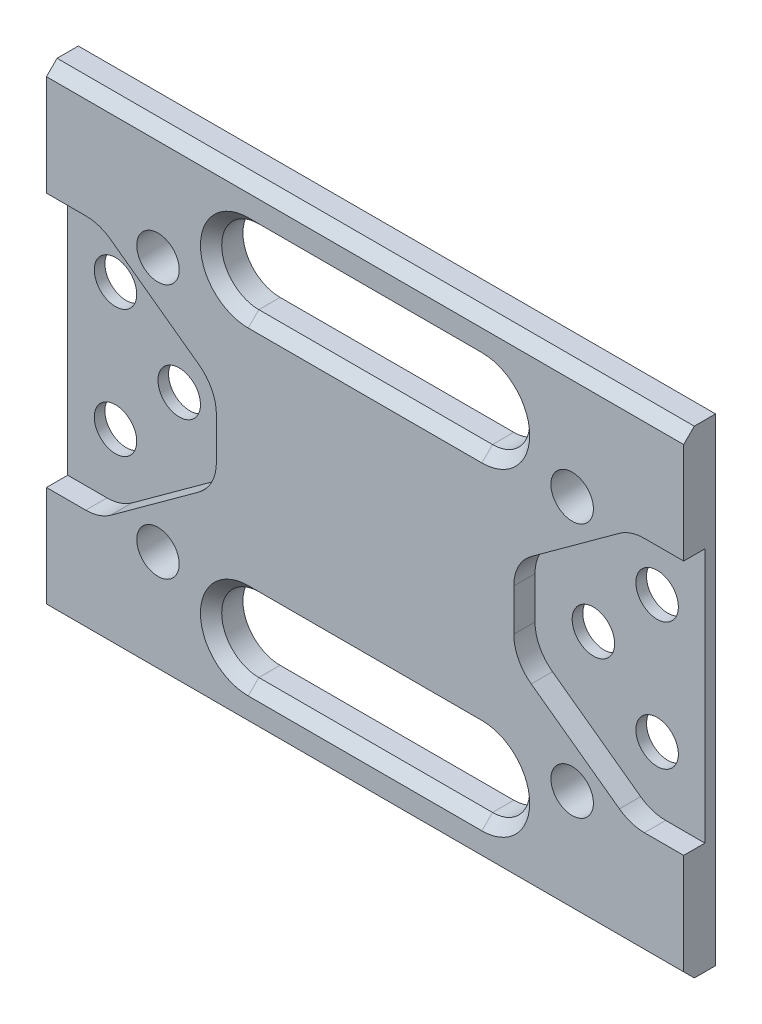
from build123d import *

# Parameters (mm, degrees)
SKETCH1_W            = 60
SKETCH1_H            = 45
BOSS_EXTRUDE1_DEPTH  = 3
SKETCH2_R            = 2
CUT_EXTRUDE1_DEPTH   = 5
CUT_EXTRUDE5_DEPTH   = 2
CUT_EXTRUDE4_DEPTH   = 5
CHAMFER2_SIZE        = 1
FILLET1_R            = 4
FILLET1_OF_MIRROR4_R = 4
CHAMFER1_SIZE        = 1


with BuildPart() as part:
    # Sketch1 → Boss-Extrude1 (new body)
    with BuildSketch(Plane.XY):
        Rectangle(SKETCH1_W, SKETCH1_H)
    extrude(amount=BOSS_EXTRUDE1_DEPTH)

    # Sketch2 → Cut-Extrude1 (cut)
    with BuildSketch(Plane(origin=(0, 0, 0), x_dir=(-1, 0, 0), z_dir=(0, 0, -1))):
        with Locations((19.5, 0)):
            Circle(SKETCH2_R)
        with Locations((25.5, 6)):
            Circle(SKETCH2_R)
        with Locations((25.5, -6)):
            Circle(SKETCH2_R)
        with Locations((19.5, -12)):
            Circle(SKETCH2_R)
        with Locations((19.5, 12)):
            Circle(SKETCH2_R)
    cut_extrude1 = extrude(amount=-CUT_EXTRUDE1_DEPTH, mode=Mode.SUBTRACT)

    # Sketch8 → Cut-Extrude5 (cut)
    with BuildSketch(Plane.XY.offset(3)):
        Polygon((-14, 4), (-14, -4), (-25, -12), (-30, -12), (-30, 12), (-25, 12), align=None)
    cut_extrude5 = extrude(amount=-CUT_EXTRUDE5_DEPTH, mode=Mode.SUBTRACT)

    # Sketch7 → Cut-Extrude4 (cut)
    with BuildSketch(Plane.XY.offset(3)):
        with BuildLine():
            Line((-11, -18.5), (9, -18.5))
            Line((9, -18.5), (9, -11.5))
            Line((9, -11.5), (-11, -11.5))
            ThreePointArc((-11, -11.5), (-14.5, -15), (-11, -18.5))
        make_face()
        with BuildLine():
            Line((-11, 11.5), (9, 11.5))
            Line((9, 11.5), (9, 18.5))
            Line((9, 18.5), (-11, 18.5))
            ThreePointArc((-11, 18.5), (-14.5, 15), (-11, 11.5))
        make_face()
    cut_extrude4 = extrude(amount=-CUT_EXTRUDE4_DEPTH, mode=Mode.SUBTRACT)

    # Chamfer2
    chamfer2_edges = [part.edges().sort_by_distance(p)[0] for p in [
        (0, -22.5, 3),
        (0, 22.5, 3),
    ]]
    chamfer(chamfer2_edges, length=CHAMFER2_SIZE)

    # Fillet1
    fillet1_edges = [part.edges().sort_by_distance(p)[0] for p in [
        (-25, 12, 2),
        (-14, 4, 2),
        (-14, -4, 2),
        (-25, -12, 2),
    ]]
    fillet(fillet1_edges, radius=FILLET1_R)

    # Mirror4: Cut-Extrude1, Cut-Extrude5, Cut-Extrude4 across plane
    add(cut_extrude1.mirror(Plane(origin=(0, 0, 0), x_dir=(0, 0, 1), z_dir=(1, 0, 0))), mode=Mode.SUBTRACT)
    add(cut_extrude5.mirror(Plane(origin=(0, 0, 0), x_dir=(0, 0, 1), z_dir=(1, 0, 0))), mode=Mode.SUBTRACT)
    add(cut_extrude4.mirror(Plane(origin=(0, 0, 0), x_dir=(0, 0, 1), z_dir=(1, 0, 0))), mode=Mode.SUBTRACT)

    # Fillet1 of Mirror4
    fillet1_of_mirror4_edges = [part.edges().sort_by_distance(p)[0] for p in [
        (25, 12, 2),
        (14, 4, 2),
        (14, -4, 2),
        (25, -12, 2),
    ]]
    fillet(fillet1_of_mirror4_edges, radius=FILLET1_OF_MIRROR4_R)

    # Chamfer1
    chamfer1_edges = [part.edges().sort_by_distance(p)[0] for p in [
        (14.5, -15, 3),
        (14.5, 15, 3),
        (-14.5, -15, 3),
        (0, -18.5, 3),
        (0, -11.5, 3),
        (0, 18.5, 3),
        (-14.5, 15, 3),
        (0, 11.5, 3),
    ]]
    chamfer(chamfer1_edges, length=CHAMFER1_SIZE)


solid = part.part
